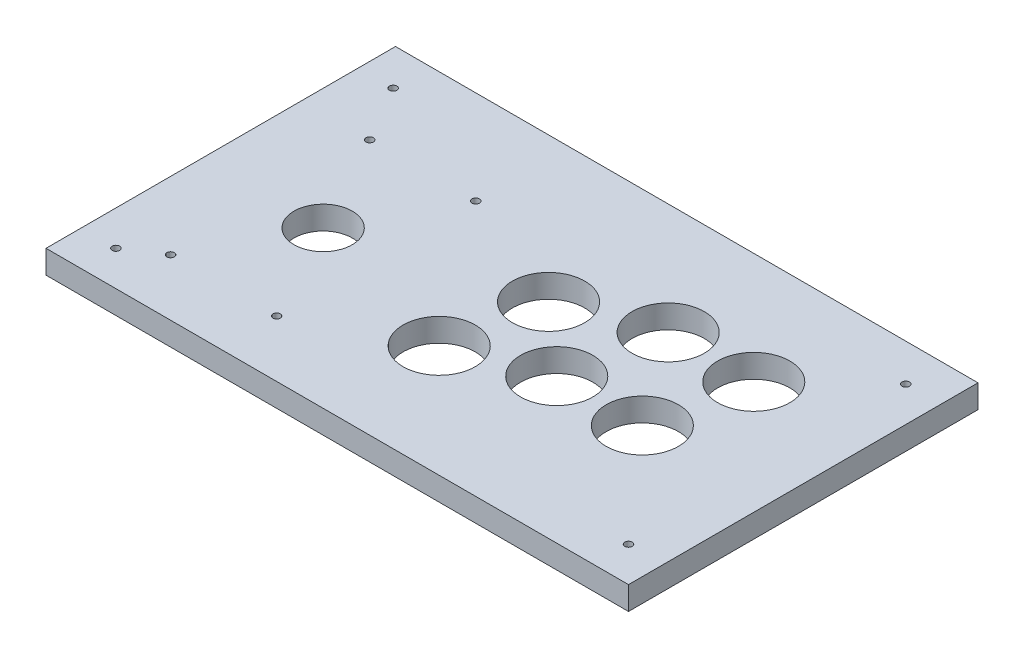
from build123d import *

# Parameters (mm, degrees)
CROQUIS1_W              = 250
CROQUIS1_H              = 150
SALIENTE_EXTRUIR1_DEPTH = 10
CORTAR_EXTRUIR1_REACH   = 12
CROQUIS2_R              = 12.5
CROQUIS2_R_2            = 15.5
CORTAR_EXTRUIR2_REACH   = 12
CROQUIS3_R              = 1.6


with BuildPart() as part:
    # Croquis1 → Saliente-Extruir1 (new body)
    with BuildSketch(Plane(origin=(0, 0, 0), x_dir=(1, 0, 0), z_dir=(0, 1, 0))):
        Rectangle(CROQUIS1_W, CROQUIS1_H)
    extrude(amount=SALIENTE_EXTRUIR1_DEPTH)

    # Croquis2 → Cortar-Extruir1 (cut, up to next)
    with BuildSketch(Plane(origin=(0, 10, 0), x_dir=(1, 0, 0), z_dir=(0, 1, 0)), mode=Mode.PRIVATE) as cortar_extruir1_sk1:
        with Locations((-73.102687588, -7.952940163)):
            Circle(CROQUIS2_R)
    cortar_extruir1_tool1 = extrude(cortar_extruir1_sk1.sketch, amount=-CORTAR_EXTRUIR1_REACH, mode=Mode.PRIVATE) & part.part
    add(cortar_extruir1_tool1.solids().sort_by_distance((-73.102688, 10, 7.95294))[0], mode=Mode.SUBTRACT)
    # Croquis2 → Cortar-Extruir1 (cut, up to next)
    with BuildSketch(Plane(origin=(0, 10, 0), x_dir=(1, 0, 0), z_dir=(0, 1, 0)), mode=Mode.PRIVATE) as cortar_extruir1_sk2:
        with Locations((-4.370803181, -26.878296525)):
            Circle(CROQUIS2_R_2)
    cortar_extruir1_tool2 = extrude(cortar_extruir1_sk2.sketch, amount=-CORTAR_EXTRUIR1_REACH, mode=Mode.PRIVATE) & part.part
    add(cortar_extruir1_tool2.solids().sort_by_distance((-4.370803, 10, 26.878297))[0], mode=Mode.SUBTRACT)
    # Croquis2 → Cortar-Extruir1 (cut, up to next)
    with BuildSketch(Plane(origin=(0, 10, 0), x_dir=(1, 0, 0), z_dir=(0, 1, 0)), mode=Mode.PRIVATE) as cortar_extruir1_sk3:
        with Locations((2.765040009, 12.93083036)):
            Circle(CROQUIS2_R_2)
    cortar_extruir1_tool3 = extrude(cortar_extruir1_sk3.sketch, amount=-CORTAR_EXTRUIR1_REACH, mode=Mode.PRIVATE) & part.part
    add(cortar_extruir1_tool3.solids().sort_by_distance((2.76504, 10, -12.93083))[0], mode=Mode.SUBTRACT)
    # Croquis2 → Cortar-Extruir1 (cut, up to next)
    with BuildSketch(Plane(origin=(0, 10, 0), x_dir=(1, 0, 0), z_dir=(0, 1, 0)), mode=Mode.PRIVATE) as cortar_extruir1_sk4:
        with Locations((39.781486463, 27.243051559)):
            Circle(CROQUIS2_R_2)
    cortar_extruir1_tool4 = extrude(cortar_extruir1_sk4.sketch, amount=-CORTAR_EXTRUIR1_REACH, mode=Mode.PRIVATE) & part.part
    add(cortar_extruir1_tool4.solids().sort_by_distance((39.781486, 10, -27.243052))[0], mode=Mode.SUBTRACT)
    # Croquis2 → Cortar-Extruir1 (cut, up to next)
    with BuildSketch(Plane(origin=(0, 10, 0), x_dir=(1, 0, 0), z_dir=(0, 1, 0)), mode=Mode.PRIVATE) as cortar_extruir1_sk5:
        with Locations((76.517860202, 27.243051559)):
            Circle(CROQUIS2_R_2)
    cortar_extruir1_tool5 = extrude(cortar_extruir1_sk5.sketch, amount=-CORTAR_EXTRUIR1_REACH, mode=Mode.PRIVATE) & part.part
    add(cortar_extruir1_tool5.solids().sort_by_distance((76.51786, 10, -27.243052))[0], mode=Mode.SUBTRACT)
    # Croquis2 → Cortar-Extruir1 (cut, up to next)
    with BuildSketch(Plane(origin=(0, 10, 0), x_dir=(1, 0, 0), z_dir=(0, 1, 0)), mode=Mode.PRIVATE) as cortar_extruir1_sk6:
        with Locations((68.851282971, -12.913044543)):
            Circle(CROQUIS2_R_2)
    cortar_extruir1_tool6 = extrude(cortar_extruir1_sk6.sketch, amount=-CORTAR_EXTRUIR1_REACH, mode=Mode.PRIVATE) & part.part
    add(cortar_extruir1_tool6.solids().sort_by_distance((68.851283, 10, 12.913045))[0], mode=Mode.SUBTRACT)
    # Croquis2 → Cortar-Extruir1 (cut, up to next)
    with BuildSketch(Plane(origin=(0, 10, 0), x_dir=(1, 0, 0), z_dir=(0, 1, 0)), mode=Mode.PRIVATE) as cortar_extruir1_sk7:
        with Locations((32.113542958, -12.913044543)):
            Circle(CROQUIS2_R_2)
    cortar_extruir1_tool7 = extrude(cortar_extruir1_sk7.sketch, amount=-CORTAR_EXTRUIR1_REACH, mode=Mode.PRIVATE) & part.part
    add(cortar_extruir1_tool7.solids().sort_by_distance((32.113543, 10, 12.913045))[0], mode=Mode.SUBTRACT)

    # Croquis3 → Cortar-Extruir2 (cut, up to next)
    with BuildSketch(Plane(origin=(0, 10, 0), x_dir=(1, 0, 0), z_dir=(0, 1, 0)), mode=Mode.PRIVATE) as cortar_extruir2_sk1:
        with Locations((-110, 59)):
            Circle(CROQUIS3_R)
    cortar_extruir2_tool1 = extrude(cortar_extruir2_sk1.sketch, amount=-CORTAR_EXTRUIR2_REACH, mode=Mode.PRIVATE) & part.part
    add(cortar_extruir2_tool1.solids().sort_by_distance((-110, 10, -59))[0], mode=Mode.SUBTRACT)
    # Croquis3 → Cortar-Extruir2 (cut, up to next)
    with BuildSketch(Plane(origin=(0, 10, 0), x_dir=(1, 0, 0), z_dir=(0, 1, 0)), mode=Mode.PRIVATE) as cortar_extruir2_sk2:
        with Locations((110, 59)):
            Circle(CROQUIS3_R)
    cortar_extruir2_tool2 = extrude(cortar_extruir2_sk2.sketch, amount=-CORTAR_EXTRUIR2_REACH, mode=Mode.PRIVATE) & part.part
    add(cortar_extruir2_tool2.solids().sort_by_distance((110, 10, -59))[0], mode=Mode.SUBTRACT)
    # Croquis3 → Cortar-Extruir2 (cut, up to next)
    with BuildSketch(Plane(origin=(0, 10, 0), x_dir=(1, 0, 0), z_dir=(0, 1, 0)), mode=Mode.PRIVATE) as cortar_extruir2_sk3:
        with Locations((110, -60)):
            Circle(CROQUIS3_R)
    cortar_extruir2_tool3 = extrude(cortar_extruir2_sk3.sketch, amount=-CORTAR_EXTRUIR2_REACH, mode=Mode.PRIVATE) & part.part
    add(cortar_extruir2_tool3.solids().sort_by_distance((110, 10, 60))[0], mode=Mode.SUBTRACT)
    # Croquis3 → Cortar-Extruir2 (cut, up to next)
    with BuildSketch(Plane(origin=(0, 10, 0), x_dir=(1, 0, 0), z_dir=(0, 1, 0)), mode=Mode.PRIVATE) as cortar_extruir2_sk4:
        with Locations((-110, -60)):
            Circle(CROQUIS3_R)
    cortar_extruir2_tool4 = extrude(cortar_extruir2_sk4.sketch, amount=-CORTAR_EXTRUIR2_REACH, mode=Mode.PRIVATE) & part.part
    add(cortar_extruir2_tool4.solids().sort_by_distance((-110, 10, 60))[0], mode=Mode.SUBTRACT)
    # Croquis3 → Cortar-Extruir2 (cut, up to next)
    with BuildSketch(Plane(origin=(0, 10, 0), x_dir=(1, 0, 0), z_dir=(0, 1, 0)), mode=Mode.PRIVATE) as cortar_extruir2_sk5:
        with Locations((-50.352687588, 34.767059837)):
            Circle(CROQUIS3_R)
    cortar_extruir2_tool5 = extrude(cortar_extruir2_sk5.sketch, amount=-CORTAR_EXTRUIR2_REACH, mode=Mode.PRIVATE) & part.part
    add(cortar_extruir2_tool5.solids().sort_by_distance((-50.352688, 10, -34.76706))[0], mode=Mode.SUBTRACT)
    # Croquis3 → Cortar-Extruir2 (cut, up to next)
    with BuildSketch(Plane(origin=(0, 10, 0), x_dir=(1, 0, 0), z_dir=(0, 1, 0)), mode=Mode.PRIVATE) as cortar_extruir2_sk6:
        with Locations((-50.352687588, -50.672940163)):
            Circle(CROQUIS3_R)
    cortar_extruir2_tool6 = extrude(cortar_extruir2_sk6.sketch, amount=-CORTAR_EXTRUIR2_REACH, mode=Mode.PRIVATE) & part.part
    add(cortar_extruir2_tool6.solids().sort_by_distance((-50.352688, 10, 50.67294))[0], mode=Mode.SUBTRACT)
    # Croquis3 → Cortar-Extruir2 (cut, up to next)
    with BuildSketch(Plane(origin=(0, 10, 0), x_dir=(1, 0, 0), z_dir=(0, 1, 0)), mode=Mode.PRIVATE) as cortar_extruir2_sk7:
        with Locations((-95.852687588, -50.672940163)):
            Circle(CROQUIS3_R)
    cortar_extruir2_tool7 = extrude(cortar_extruir2_sk7.sketch, amount=-CORTAR_EXTRUIR2_REACH, mode=Mode.PRIVATE) & part.part
    add(cortar_extruir2_tool7.solids().sort_by_distance((-95.852688, 10, 50.67294))[0], mode=Mode.SUBTRACT)
    # Croquis3 → Cortar-Extruir2 (cut, up to next)
    with BuildSketch(Plane(origin=(0, 10, 0), x_dir=(1, 0, 0), z_dir=(0, 1, 0)), mode=Mode.PRIVATE) as cortar_extruir2_sk8:
        with Locations((-95.852687588, 34.767059837)):
            Circle(CROQUIS3_R)
    cortar_extruir2_tool8 = extrude(cortar_extruir2_sk8.sketch, amount=-CORTAR_EXTRUIR2_REACH, mode=Mode.PRIVATE) & part.part
    add(cortar_extruir2_tool8.solids().sort_by_distance((-95.852688, 10, -34.76706))[0], mode=Mode.SUBTRACT)


solid = part.part
